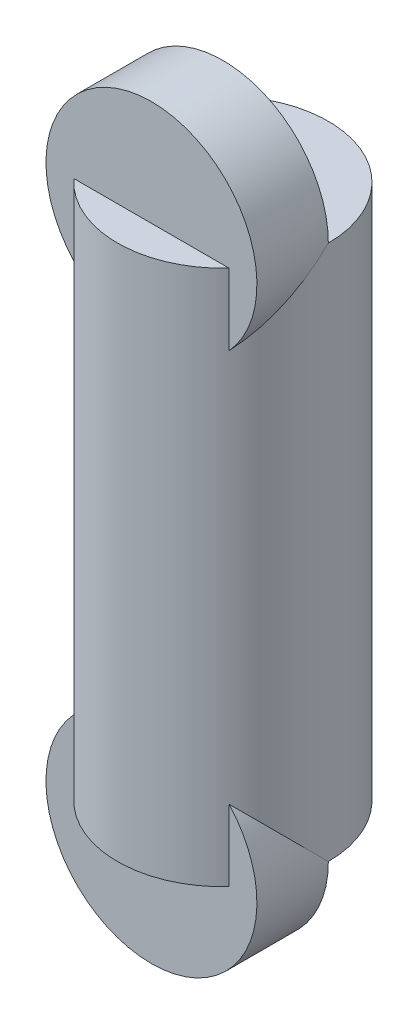
from build123d import *

# Parameters (mm, degrees)
SKETCH1_W           = 14.417582417
SKETCH1_H           = 150
SKETCH2_R           = 29.538461538
BOSS_EXTRUDE1_DEPTH = 20


with BuildPart() as part:
    # Sketch1 → Revolve1 (revolve)
    with BuildSketch(Plane.XY):
        with Locations((22.32967033, 41.065934066)):
            Rectangle(SKETCH1_W, SKETCH1_H)
    revolve(axis=Axis((0, 46.065934066, 0), (0, -1, 0)))

    # Sketch2 → Boss-Extrude1 (add)
    with BuildSketch(Plane.XY):
        with Locations((0, 116.065934066)):
            Circle(SKETCH2_R)
        with Locations((0, -33.934065934)):
            Circle(SKETCH2_R)
    extrude(amount=BOSS_EXTRUDE1_DEPTH)


solid = part.part
